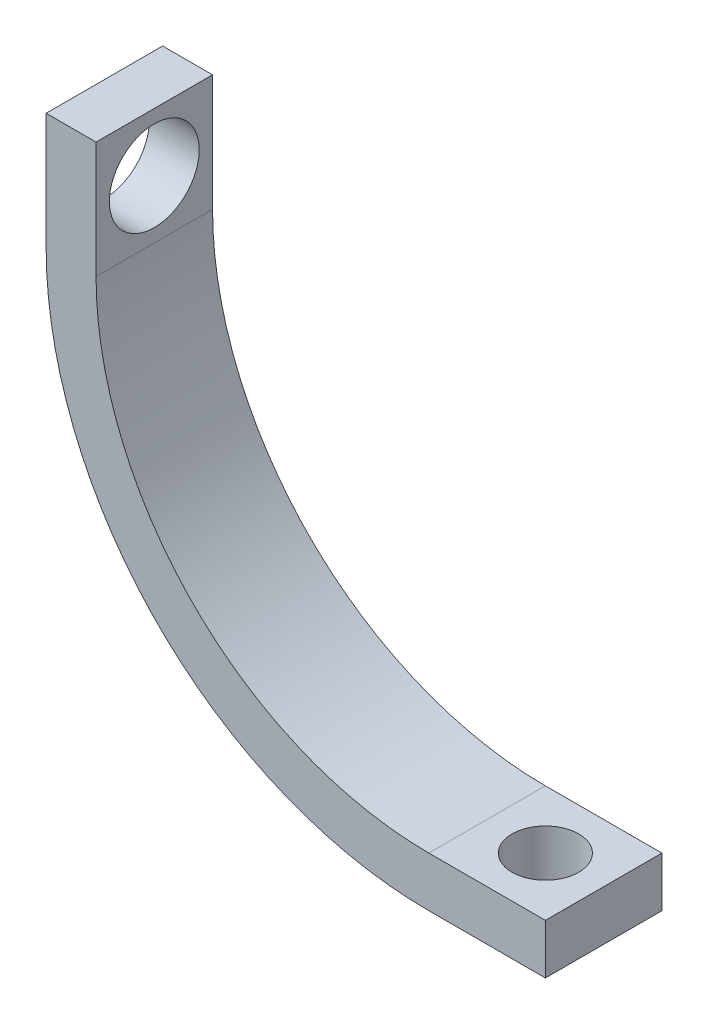
from build123d import *

# Parameters (mm, degrees)
BOSS_EXTRUDE1_DEPTH = 7
SKETCH2_R           = 2.7
CUT_EXTRUDE1_DEPTH  = 4
SKETCH4_R           = 2
CUT_EXTRUDE2_DEPTH  = 10


with BuildPart() as part:
    # Sketch1 → Boss-Extrude1 (new body)
    with BuildSketch(Plane.XY):
        with BuildLine():
            Line((-20, 0), (-20, 7))
            Line((-20, 7), (-23, 7))
            Line((-23, 7), (-23, 0))
            ThreePointArc((-23, 0), (-16.263455967, -16.263455967), (0, -23))
            Line((0, -23), (7, -23))
            Line((7, -23), (7, -20))
            Line((7, -20), (0, -20))
            ThreePointArc((0, -20), (-14.142135624, -14.142135624), (-20, 0))
        make_face()
    extrude(amount=BOSS_EXTRUDE1_DEPTH)

    # Sketch2 → Cut-Extrude1 (cut, through all)
    with BuildSketch(Plane(origin=(-20, 0, 0), x_dir=(0, 0, -1), z_dir=(1, 0, 0))):
        with Locations((-3.5, 3.5)):
            Circle(SKETCH2_R)
    extrude(amount=-CUT_EXTRUDE1_DEPTH, mode=Mode.SUBTRACT)

    # Sketch4 → Cut-Extrude2 (cut)
    with BuildSketch(Plane(origin=(0, -20, 0), x_dir=(1, 0, 0), z_dir=(0, 1, 0))):
        with Locations((3.5, -3.5)):
            Circle(SKETCH4_R)
    extrude(amount=-CUT_EXTRUDE2_DEPTH, mode=Mode.SUBTRACT)


solid = part.part
